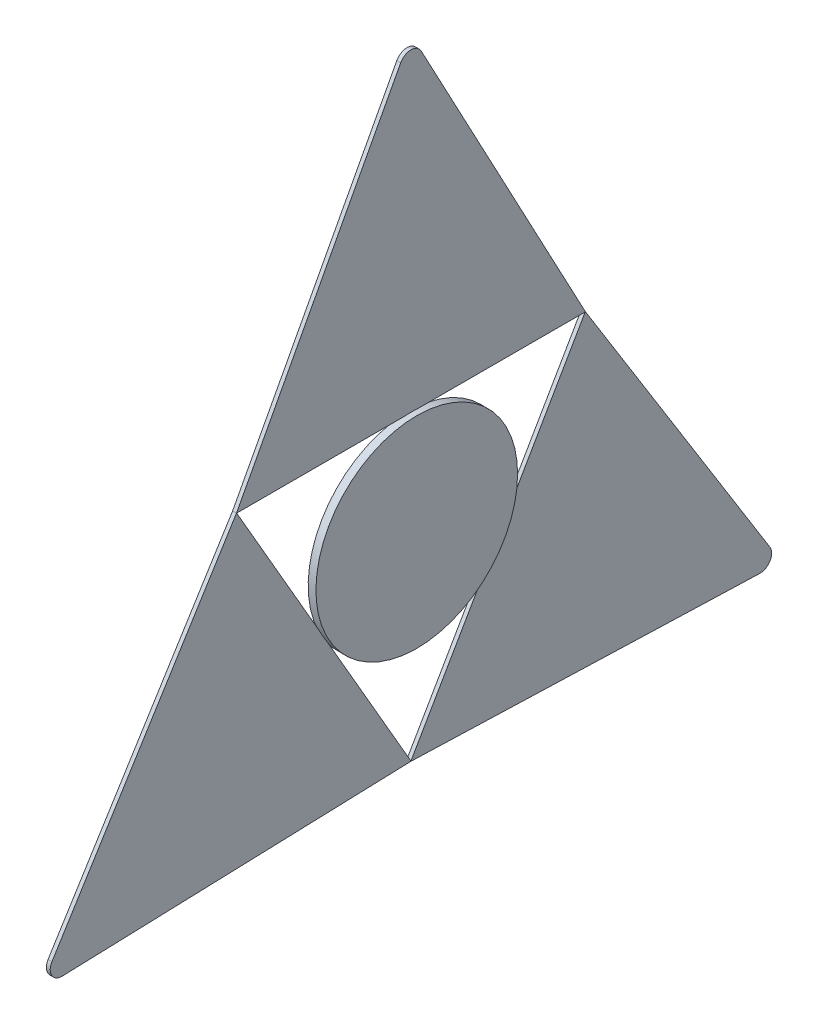
from build123d import *

# Parameters (mm, degrees)
BOSS_EXTRUDE1_DEPTH = 0.25
SKETCH2_R           = 13
BOSS_EXTRUDE2_DEPTH = 1
CIRPATTERN1_COUNT   = 3
SKETCH4_W           = 10
SKETCH4_H           = 10
BOSS_EXTRUDE3_DEPTH = 2


with BuildPart() as part:
    # Sketch1 → Boss-Extrude1 (new body, symmetric)
    with BuildSketch(Plane(origin=(0, 0, 0), x_dir=(0, 0, -1), z_dir=(1, 0, 0))):
        with BuildLine():
            Line((-1.323529412, 0.705882353), (-22.5, -39))
            Line((-22.5, -39), (22.5, -39))
            Line((22.5, -39), (1.323529412, 0.705882353))
            ThreePointArc((1.323529412, 0.705882353), (0, 1.5), (-1.323529412, 0.705882353))
        make_face()
    boss_extrude1 = extrude(amount=BOSS_EXTRUDE1_DEPTH, both=True)

    # Sketch2 → Boss-Extrude2 (add)
    with BuildSketch(Plane(origin=(0, 0, 0), x_dir=(0, 0, -1), z_dir=(1, 0, 0))):
        with Locations((0, -51.97114317)):
            Circle(SKETCH2_R)
    extrude(amount=BOSS_EXTRUDE2_DEPTH)

    # CirPattern1: Boss-Extrude1 ×3 about axis
    cirpattern1_axis = Axis((0, -51.97114317, 0), (1, 0, 0))
    for i in range(1, CIRPATTERN1_COUNT):
        add(boss_extrude1.rotate(cirpattern1_axis, i * 360 / CIRPATTERN1_COUNT))

    # Sketch4 → Boss-Extrude3 (add)
    with BuildSketch(Plane.ZY):
        with Locations((0, -51.97114317)):
            Rectangle(SKETCH4_W, SKETCH4_H)
    extrude(amount=BOSS_EXTRUDE3_DEPTH)


solid = part.part
